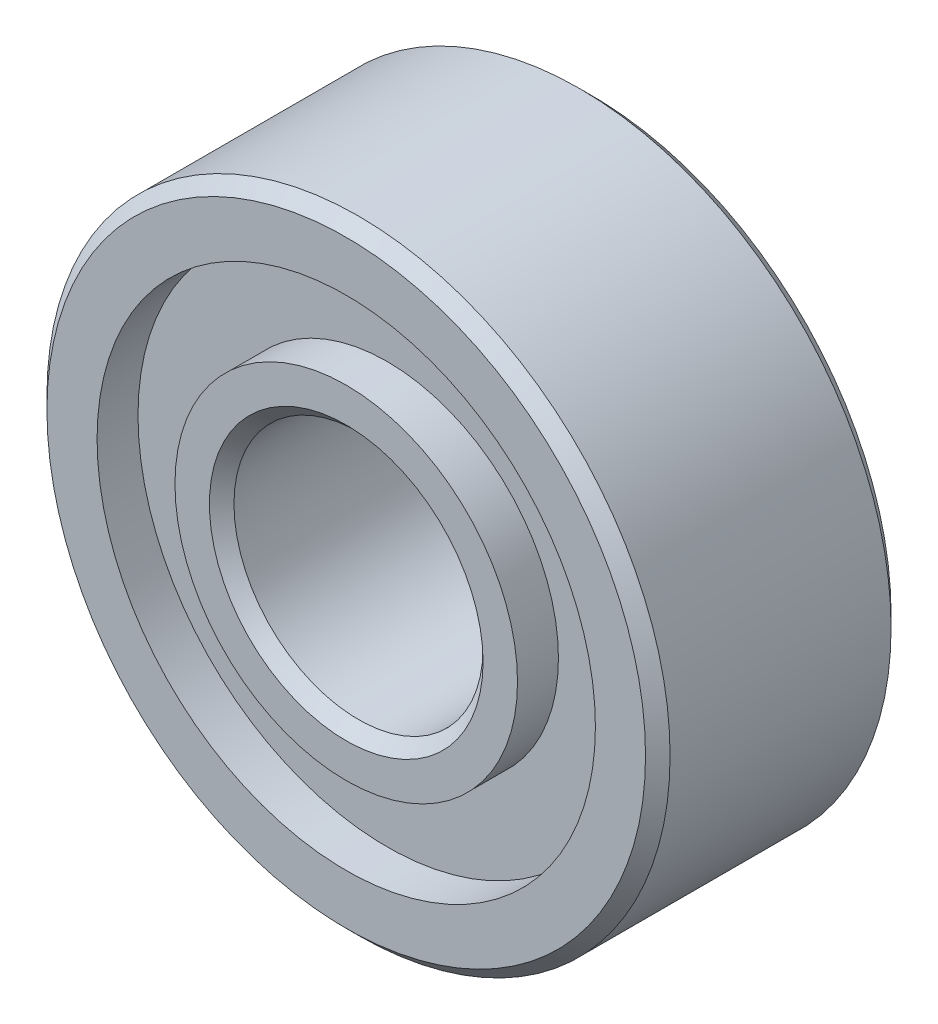
from build123d import *

# Parameters (mm, degrees)
SKETCH1_R      = 5
EXTRUDE1_DEPTH = 3.94
HOLE1_D        = 7.996833333
HOLE1_DEPTH    = 0.656666667
SKETCH4_R      = 2.748625
EXTRUDE2_DEPTH = 0.656666667
HOLE2_D        = 7.996833333
HOLE2_DEPTH    = 0.656666667
SKETCH7_R      = 2.748625
EXTRUDE3_DEPTH = 0.656666667
HOLE3_D        = 3.9975
HOLE3_DEPTH    = 3.94
CHAMFER1_SIZE  = 0.197


with BuildPart() as part:
    # Sketch1 → Extrude1 (new body)
    with BuildSketch(Plane.XY.offset(3.94)):
        Circle(SKETCH1_R)
    extrude(amount=-EXTRUDE1_DEPTH)

    # Hole1
    with Locations(Plane.XY.offset(3.94)):
        with Locations((0, 0)):
            Hole(HOLE1_D / 2, depth=HOLE1_DEPTH)

    # Sketch4 → Extrude2 (add)
    with BuildSketch(Plane.XY.offset(3.283333333)):
        Circle(SKETCH4_R)
    extrude(amount=EXTRUDE2_DEPTH)

    # Hole2
    with Locations(Plane(origin=(0, 0, 0), x_dir=(-1, 0, 0), z_dir=(0, 0, -1))):
        with Locations((0, 0)):
            Hole(HOLE2_D / 2, depth=HOLE2_DEPTH)

    # Sketch7 → Extrude3 (add)
    with BuildSketch(Plane(origin=(0, 0, 0.656666667), x_dir=(-1, 0, 0), z_dir=(0, 0, -1))):
        Circle(SKETCH7_R)
    extrude(amount=EXTRUDE3_DEPTH)

    # Hole3
    with Locations(Plane(origin=(0, 0, 0), x_dir=(-1, 0, 0), z_dir=(0, 0, -1))):
        with Locations((0, 0)):
            Hole(HOLE3_D / 2, depth=HOLE3_DEPTH)

    # Chamfer1
    chamfer1_edges = [part.edges().sort_by_distance(p)[0] for p in [
        (-5, 0, 3.94),
        (-1.99875, 0, 0),
        (-1.99875, 0, 3.94),
        (-5, 0, 0),
    ]]
    chamfer(chamfer1_edges, length=CHAMFER1_SIZE)


solid = part.part
